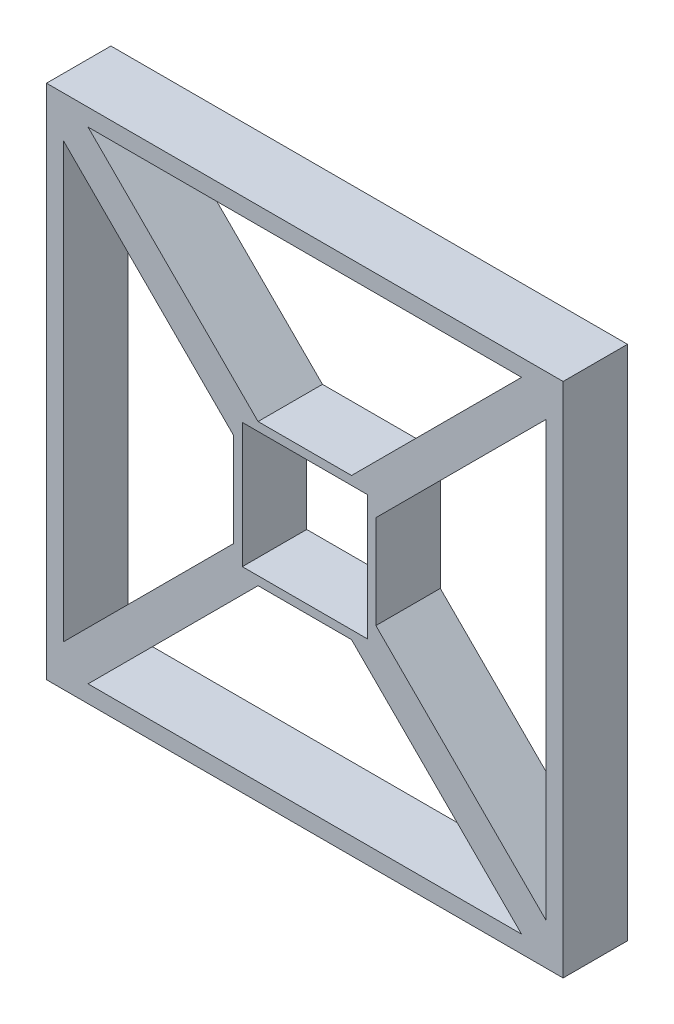
from build123d import *

# Parameters (mm, degrees)
SKETCH1_W           = 6000
SKETCH1_H           = 6000
SKETCH1_W_2         = 1451.222297848
SKETCH1_H_2         = 1451.222297848
BOSS_EXTRUDE1_DEPTH = 748


with BuildPart() as part:
    # Sketch1 → Boss-Extrude1 (new body)
    with BuildSketch(Plane.XY):
        Rectangle(SKETCH1_W, SKETCH1_H)
        Polygon((-2517.157287525, 2800), (2517.157287525, 2800), (542.768436449, 825.611148924), (-542.768436449, 825.611148924), align=None, mode=Mode.SUBTRACT)
        Polygon((2800, 2517.157287525), (2800, -2517.157287525), (825.611148924, -542.768436449), (825.611148924, 542.768436449), align=None, mode=Mode.SUBTRACT)
        Polygon((-2517.157287525, -2800), (2517.157287525, -2800), (542.768436449, -825.611148924), (-542.768436449, -825.611148924), align=None, mode=Mode.SUBTRACT)
        Polygon((-2800, 2517.157287525), (-2800, -2517.157287525), (-825.611148924, -542.768436449), (-825.611148924, 542.768436449), align=None, mode=Mode.SUBTRACT)
        Rectangle(SKETCH1_W_2, SKETCH1_H_2, mode=Mode.SUBTRACT)
    extrude(amount=BOSS_EXTRUDE1_DEPTH)


solid = part.part
